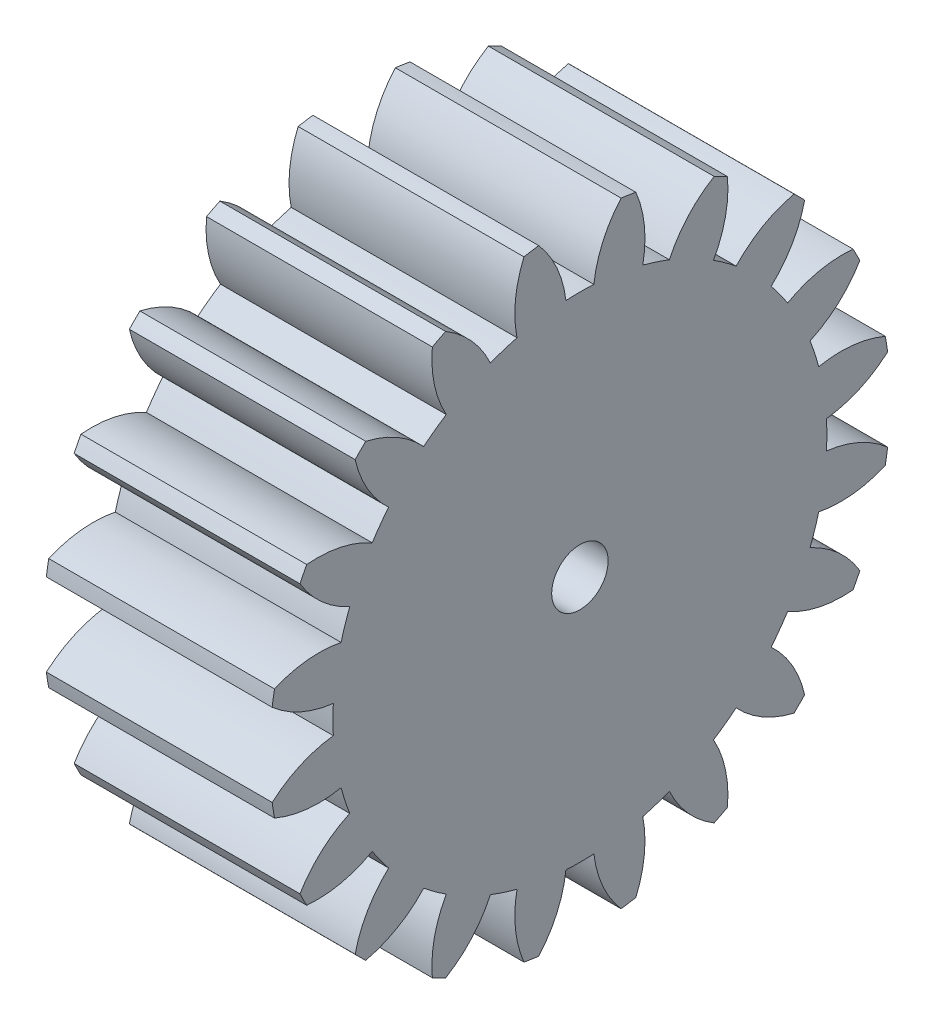
from build123d import *

# Parameters (mm, degrees)
BASPROSKE_W     = 20
BASPROSKE_H     = 27.5
TOOTHCUT_DEPTH  = 44.732139211
TEETHCUTS_COUNT = 20
TEETHCUTS_ANGLE = 342
BORSKE_R        = 2.5
BORE_DEPTH      = 50.0000508


with BuildPart() as part:
    # BasProSke → Base-Revolve (revolve)
    with BuildSketch(Plane(origin=(0, 0, 0), x_dir=(1, 0, 0), z_dir=(0, 1, 0)), mode=Mode.PRIVATE) as base_revolve_sk:
        with Locations((10, 13.75)):
            Rectangle(BASPROSKE_W, BASPROSKE_H)
    revolve(base_revolve_sk.sketch.rotate(Axis((-10, 0, 0), (1, 0, 0)), 180), axis=Axis((-10, 0, 0), (1, 0, 0)))

    # TooCutSke → ToothCut (cut, through all)
    with BuildSketch(Plane(origin=(0, 0, 0), x_dir=(0, 0, -1), z_dir=(1, 0, 0))):
        with BuildLine():
            ThreePointArc((1.237725267, 21.838954008), (0, 21.874), (-1.237725267, 21.838954008))
            ThreePointArc((-1.237725267, 21.838954008), (-2.037783758, 24.744650423), (-3.667234079, 27.280011719))
            ThreePointArc((-3.667234079, 27.280011719), (0, 27.5254), (3.667234079, 27.280011719))
            ThreePointArc((3.667234079, 27.280011719), (2.037783758, 24.744650423), (1.237725267, 21.838954008))
        make_face()
    toothcut = extrude(amount=TOOTHCUT_DEPTH, mode=Mode.SUBTRACT)

    # TeethCuts: ToothCut ×20 about axis
    teethcuts_axis = Axis((-10, 0, 0), (1, 0, 0))
    for i in range(1, TEETHCUTS_COUNT):
        add(toothcut.rotate(teethcuts_axis, i * TEETHCUTS_ANGLE / (TEETHCUTS_COUNT - 1)), mode=Mode.SUBTRACT)

    # BorSke → Bore (cut, symmetric)
    with BuildSketch(Plane(origin=(0, 0, 0), x_dir=(0, 0, -1), z_dir=(1, 0, 0))):
        with Locations(Location((0, 0, 0), (0, 0, 180))):
            Circle(BORSKE_R)
    extrude(amount=BORE_DEPTH, both=True, mode=Mode.SUBTRACT)


solid = part.part
